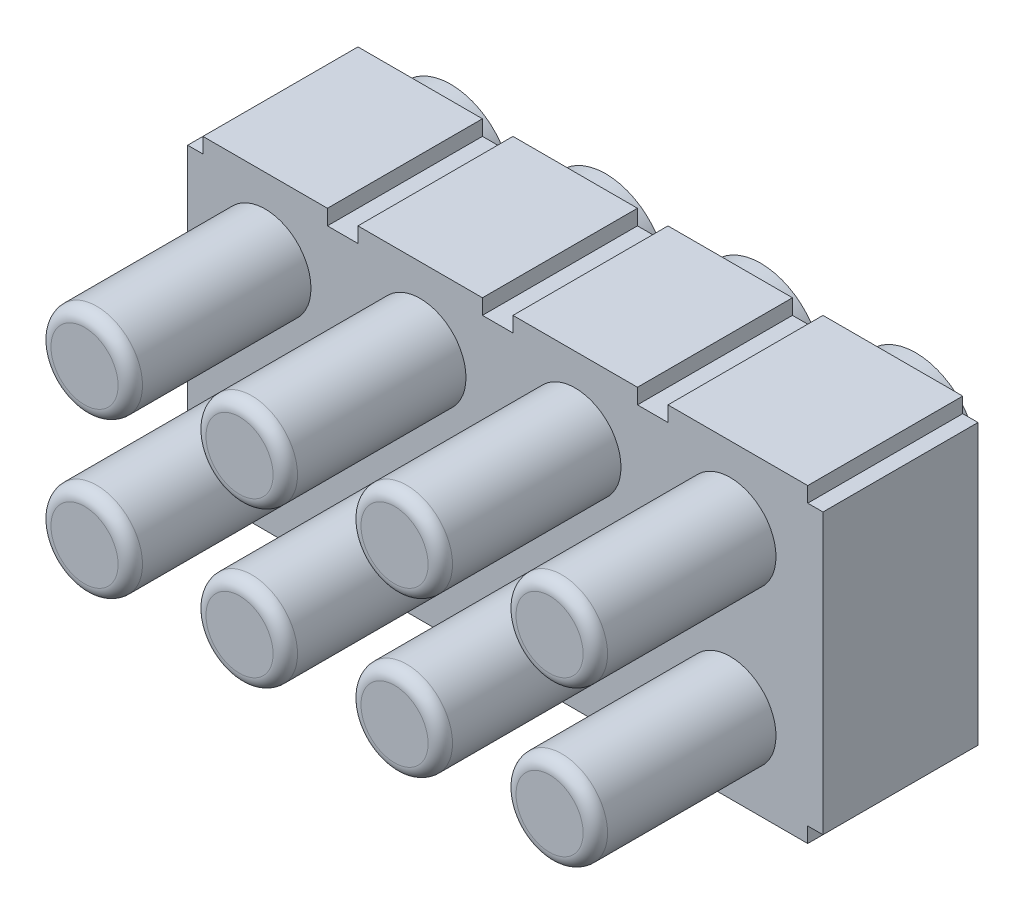
from build123d import *

# Parameters (mm, degrees)
EXTRUDE_1_DEPTH     = 2.54
SKETCH_2_R          = 1
EXTRUDE_2_DEPTH     = 0.5
SKETCH_3_R          = 0.75
EXTRUDE_3_DEPTH     = 8
SKETCH_4_R          = 0.45
EXTRUDE_4_DEPTH     = 2
FILLET_1_R          = 0.4
FILLET_2_R          = 0.2
SKETCH_6_R          = 7.818087931
CUT_EXTRUDE_1_DEPTH = 4
FILLET_3_R          = 0.2


with BuildPart() as part:
    # 草图1 → 凸台-拉伸1 (new body)
    with BuildSketch(Plane.XY):
        Polygon((5.08, 2.29), (5.08, 2.54), (2.79, 2.54), (2.79, 2.29), (2.29, 2.29), (2.29, 2.54), (0.25, 2.54), (0.25, 2.29), (-0.25, 2.29), (-0.25, 2.54), (-2.29, 2.54), (-2.29, 2.29), (-2.79, 2.29), (-2.79, 2.54), (-4.83, 2.54), (-4.83, 2.29), (-5.08, 2.29), (-5.08, -2.29), (-4.83, -2.29), (-4.83, -2.54), (-2.79, -2.54), (-2.79, -2.29), (-2.29, -2.29), (-2.29, -2.54), (-0.25, -2.54), (-0.25, -2.29), (0.25, -2.29), (0.25, -2.54), (2.29, -2.54), (2.29, -2.29), (2.79, -2.29), (2.79, -2.54), (5.08, -2.54), (5.08, -2.29), (5.33, -2.29), (5.33, 0), (5.33, 2.29), align=None)
    extrude(amount=EXTRUDE_1_DEPTH)

    # 草图2 → 凸台-拉伸2 (add)
    with BuildSketch(Plane(origin=(0, 0, 0), x_dir=(-1, 0, 0), z_dir=(0, 0, -1))):
        with Locations((-1.27, 1.27)):
            Circle(SKETCH_2_R)
        with Locations((1.27, 1.27)):
            Circle(SKETCH_2_R)
        with Locations((3.81, 1.27)):
            Circle(SKETCH_2_R)
        with Locations((1.27, -1.27)):
            Circle(SKETCH_2_R)
        with Locations((3.81, -1.27)):
            Circle(SKETCH_2_R)
        with Locations((-1.27, -1.27)):
            Circle(SKETCH_2_R)
        with Locations((-3.81, 1.27)):
            Circle(SKETCH_2_R)
        with Locations((-3.81, -1.27)):
            Circle(SKETCH_2_R)
    extrude(amount=EXTRUDE_2_DEPTH)

    # 草图3 → 凸台-拉伸3 (add)
    with BuildSketch(Plane(origin=(0, 0, -0.5), x_dir=(-1, 0, 0), z_dir=(0, 0, -1))):
        with Locations((-3.81, 1.27)):
            Circle(SKETCH_3_R)
        with Locations((-1.27, 1.27)):
            Circle(SKETCH_3_R)
        with Locations((1.27, 1.27)):
            Circle(SKETCH_3_R)
        with Locations((3.81, 1.27)):
            Circle(SKETCH_3_R)
        with Locations((-1.27, -1.27)):
            Circle(SKETCH_3_R)
        with Locations((1.27, -1.27)):
            Circle(SKETCH_3_R)
        with Locations((3.81, -1.27)):
            Circle(SKETCH_3_R)
        with Locations((-3.81, -1.27)):
            Circle(SKETCH_3_R)
    extrude(amount=-EXTRUDE_3_DEPTH)

    # 草图4 → 凸台-拉伸4 (add)
    with BuildSketch(Plane.XY.offset(7.5)):
        with Locations((-3.81, 1.27)):
            Circle(SKETCH_4_R)
        with Locations((-1.27, 1.27)):
            Circle(SKETCH_4_R)
        with Locations((1.27, 1.27)):
            Circle(SKETCH_4_R)
        with Locations((3.81, 1.27)):
            Circle(SKETCH_4_R)
        with Locations((-1.27, -1.27)):
            Circle(SKETCH_4_R)
        with Locations((1.27, -1.27)):
            Circle(SKETCH_4_R)
        with Locations((3.81, -1.27)):
            Circle(SKETCH_4_R)
        with Locations((-3.81, -1.27)):
            Circle(SKETCH_4_R)
    extrude(amount=EXTRUDE_4_DEPTH)

    # 圆角1
    fillet_1_edges = [part.edges().sort_by_distance(p)[0] for p in [
        (-4.26, 1.27, 9.5),
        (-1.72, 1.27, 9.5),
        (0.82, 1.27, 9.5),
        (3.36, 1.27, 9.5),
        (-1.72, -1.27, 9.5),
        (0.82, -1.27, 9.5),
        (3.36, -1.27, 9.5),
        (-4.26, -1.27, 9.5),
    ]]
    fillet(fillet_1_edges, radius=FILLET_1_R)

    # 圆角2
    fillet_2_edges = [part.edges().sort_by_distance(p)[0] for p in [
        (4.56, 1.27, 7.5),
        (2.02, 1.27, 7.5),
        (-0.52, 1.27, 7.5),
        (-3.06, 1.27, 7.5),
        (2.02, -1.27, 7.5),
        (-0.52, -1.27, 7.5),
        (-3.06, -1.27, 7.5),
        (4.56, -1.27, 7.5),
    ]]
    fillet(fillet_2_edges, radius=FILLET_2_R)

    # 草图6 → 切除-拉伸1 (cut)
    with BuildSketch(Plane.XY.offset(9.5)):
        Circle(SKETCH_6_R)
    extrude(amount=-CUT_EXTRUDE_1_DEPTH, mode=Mode.SUBTRACT)

    # 圆角3
    fillet_3_edges = [part.edges().sort_by_distance(p)[0] for p in [
        (4.56, 1.27, 5.5),
        (2.02, 1.27, 5.5),
        (-0.52, 1.27, 5.5),
        (-3.06, 1.27, 5.5),
        (2.02, -1.27, 5.5),
        (-0.52, -1.27, 5.5),
        (-3.06, -1.27, 5.5),
        (4.56, -1.27, 5.5),
    ]]
    fillet(fillet_3_edges, radius=FILLET_3_R)


solid = part.part
